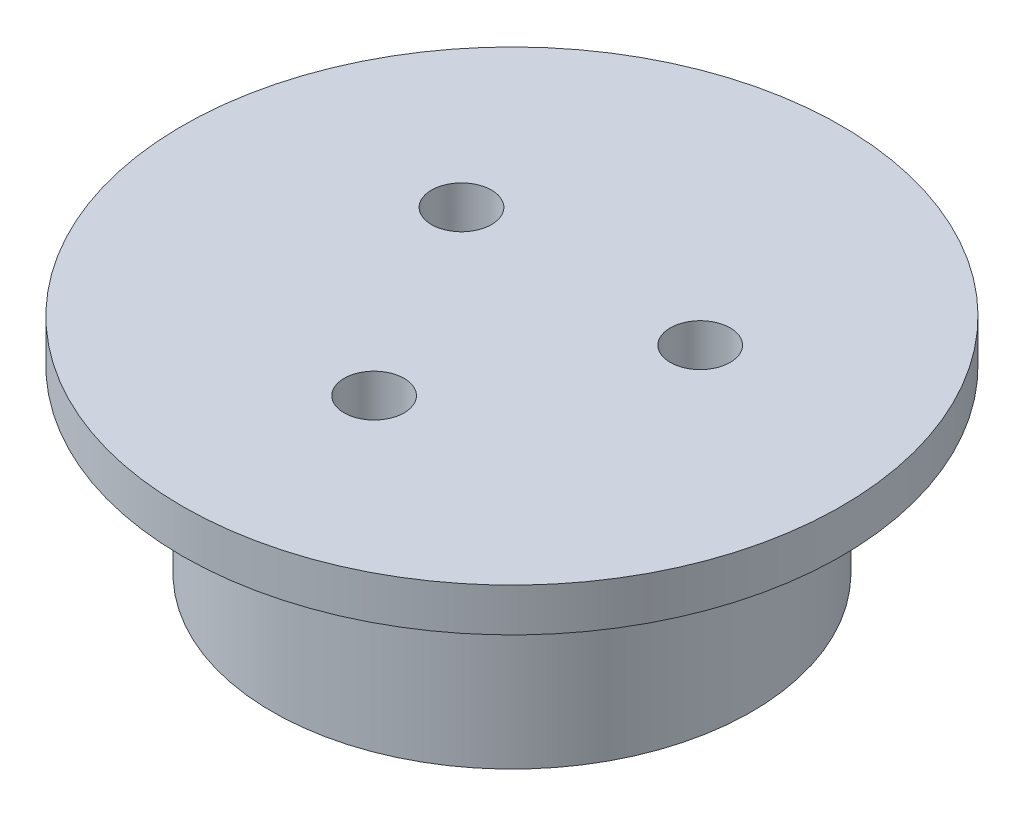
from build123d import *

# Parameters (mm, degrees)
SKETCH1_R           = 27.5
SKETCH1_R_2         = 2.5
BOSS_EXTRUDE1_DEPTH = 3.6
SKETCH2_R           = 20
SKETCH2_R_2         = 2.5
BOSS_EXTRUDE2_DEPTH = 15
SKETCH3_R           = 17.5
CUT_EXTRUDE1_DEPTH  = 5


with BuildPart() as part:
    # Sketch1 → Boss-Extrude1 (new body)
    with BuildSketch(Plane(origin=(0, 0, 0), x_dir=(1, 0, 0), z_dir=(0, 1, 0))):
        Circle(SKETCH1_R)
        with Locations((-9.959292144, 5.75)):
            Circle(SKETCH1_R_2, mode=Mode.SUBTRACT)
        with Locations((9.959292144, 5.75)):
            Circle(SKETCH1_R_2, mode=Mode.SUBTRACT)
        with Locations((0, -11.5)):
            Circle(SKETCH1_R_2, mode=Mode.SUBTRACT)
    extrude(amount=BOSS_EXTRUDE1_DEPTH)

    # Sketch2 → Boss-Extrude2 (add)
    with BuildSketch(Plane.XZ):
        Circle(SKETCH2_R)
        with Locations((0, 11.5)):
            Circle(SKETCH2_R_2, mode=Mode.SUBTRACT)
        with Locations((9.959292144, -5.75)):
            Circle(SKETCH2_R_2, mode=Mode.SUBTRACT)
        with Locations((-9.959292144, -5.75)):
            Circle(SKETCH2_R_2, mode=Mode.SUBTRACT)
    extrude(amount=BOSS_EXTRUDE2_DEPTH)

    # Sketch3 → Cut-Extrude1 (cut)
    with BuildSketch(Plane.XZ.offset(15)):
        Circle(SKETCH3_R)
    extrude(amount=-CUT_EXTRUDE1_DEPTH, mode=Mode.SUBTRACT)


solid = part.part
